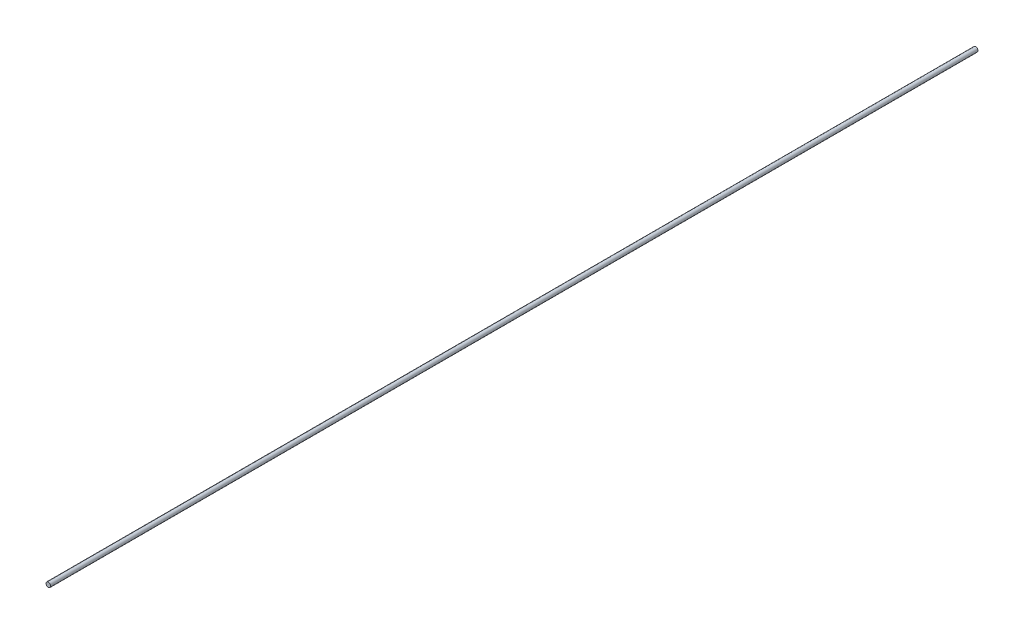
from build123d import *

# Parameters (mm, degrees)
ESQUISSE1_R        = 2
BOSS_EXTRU_1_DEPTH = 800


with BuildPart() as part:
    # Esquisse1 → Boss.-Extru.1 (new body)
    with BuildSketch(Plane.XY):
        Circle(ESQUISSE1_R)
    extrude(amount=BOSS_EXTRU_1_DEPTH)


solid = part.part
